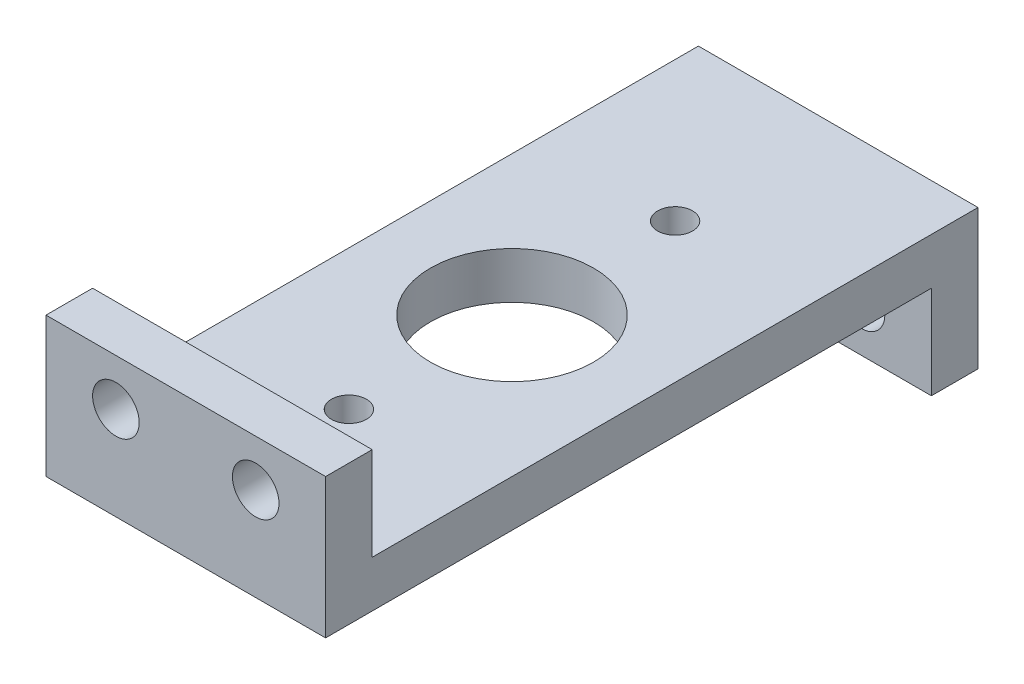
from build123d import *

# Parameters (mm, degrees)
BOSS_EXTRUDE1_DEPTH = 76.2
SKETCH3_R           = 6.35
CUT_EXTRUDE1_DEPTH  = 76.2
SKETCH4_R           = 6.35
CUT_EXTRUDE2_DEPTH  = 76.2
SKETCH5_R           = 22.225
SKETCH5_R_2         = 4.7625
CUT_EXTRUDE3_DEPTH  = 76.2


with BuildPart() as part:
    # Sketch2 → Boss-Extrude1 (new body)
    with BuildSketch(Plane(origin=(0, 0, 0), x_dir=(0, 0, -1), z_dir=(1, 0, 0))):
        Polygon((-78.818556701, -25.334536082), (86.281443299, -25.334536082), (86.281443299, -50.734536082), (98.981443299, -50.734536082), (98.981443299, -25.334536082), (98.981443299, -12.634536082), (-66.118556701, -12.634536082), (-66.118556701, 12.765463918), (-78.818556701, 12.765463918), (-78.818556701, -6.875900942), align=None)
    extrude(amount=BOSS_EXTRUDE1_DEPTH)

    # Sketch3 → Cut-Extrude1 (cut)
    with BuildSketch(Plane(origin=(0, 0, -98.981443299), x_dir=(-1, 0, 0), z_dir=(0, 0, -1))):
        with Locations((-57.15, -38.034536082)):
            Circle(SKETCH3_R)
        with Locations((-19.05, -38.034536082)):
            Circle(SKETCH3_R)
    extrude(amount=-CUT_EXTRUDE1_DEPTH, mode=Mode.SUBTRACT)

    # Sketch4 → Cut-Extrude2 (cut)
    with BuildSketch(Plane(origin=(0, 0, 66.118556701), x_dir=(-1, 0, 0), z_dir=(0, 0, -1))):
        with Locations((-57.15, 0.065463918)):
            Circle(SKETCH4_R)
        with Locations((-19.05, 0.065463918)):
            Circle(SKETCH4_R)
    extrude(amount=-CUT_EXTRUDE2_DEPTH, mode=Mode.SUBTRACT)

    # Sketch5 → Cut-Extrude3 (cut)
    with BuildSketch(Plane(origin=(0, -12.634536082, 0), x_dir=(1, 0, 0), z_dir=(0, 1, 0))):
        with Locations((38.1, 10.081443299)):
            Circle(SKETCH5_R)
        with Locations((38.1, 54.531443299)):
            Circle(SKETCH5_R_2)
        with Locations((38.1, -34.368556701)):
            Circle(SKETCH5_R_2)
    extrude(amount=-CUT_EXTRUDE3_DEPTH, mode=Mode.SUBTRACT)


solid = part.part
